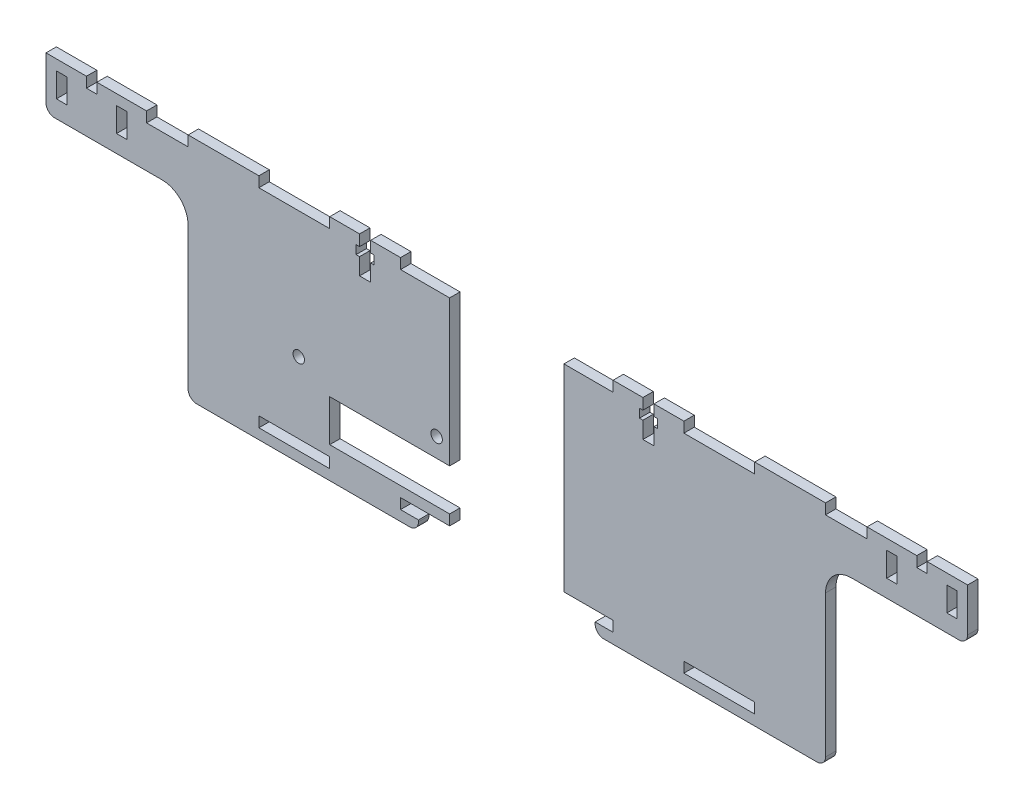
from build123d import *

# Parameters (mm, degrees)
BOSS_EXTRUDE1_DEPTH     = 3
SKETCH3_W               = 3
SKETCH3_H               = 7
SKETCH3_W_2             = 20.444444445
SKETCH3_H_2             = 3
CUT_EXTRUDE1_DEPTH      = 1
CUT_EXTRUDE1_DEPTH_BACK = 4
FILLET1_R               = 7.5
SKETCH4_W               = 3.2
SKETCH4_H               = 10.5
SKETCH4_W_2             = 5.2
SKETCH4_H_2             = 2.5
CUT_EXTRUDE2_DEPTH      = 1
CUT_EXTRUDE2_DEPTH_BACK = 4
SKETCH5_W               = 33
SKETCH5_H               = 66
CUT_EXTRUDE3_DEPTH      = 1
CUT_EXTRUDE3_DEPTH_BACK = 4
SKETCH6_R               = 1.65
SKETCH6_W               = 34.611111111
SKETCH6_H               = 12
CUT_EXTRUDE4_DEPTH      = 1
CUT_EXTRUDE4_DEPTH_BACK = 4
SKETCH9_W               = 9
SKETCH9_H               = 3
CUT_EXTRUDE7_DEPTH      = 1
CUT_EXTRUDE7_DEPTH_BACK = 4
FILLET2_R               = 2.5
FILLET3_R               = 2.5
SKETCH7_W               = 3
SKETCH7_H               = 3
SKETCH7_W_2             = 10
CUT_EXTRUDE5_DEPTH      = 4
CUT_EXTRUDE5_DEPTH_BACK = 1
SKETCH8_W               = 2
SKETCH8_H               = 3
CUT_EXTRUDE6_DEPTH      = 1
CUT_EXTRUDE6_DEPTH_BACK = 4


with BuildPart() as part:
    # Sketch2 → Boss-Extrude1 (new body)
    with BuildSketch(Plane.XY):
        Polygon((-133, 33), (133, 33), (133, 18), (92, 18), (92, -33), (-92, -33), (-92, 18), (-133, 18), align=None)
    extrude(amount=BOSS_EXTRUDE1_DEPTH)

    # Sketch3 → Cut-Extrude1 (cut, two sides)
    with BuildSketch(Plane.XY.offset(3)) as cut_extrude1_sk:
        with Locations((-128.5, 26.5)):
            Rectangle(SKETCH3_W, SKETCH3_H)
        with Locations((-111.15, 26.5)):
            Rectangle(SKETCH3_W, SKETCH3_H)
        with Locations((-61.333333334, 31.5)):
            Rectangle(SKETCH3_W_2, SKETCH3_H_2)
        with Locations((-20.444444445, 31.5)):
            Rectangle(SKETCH3_W_2, SKETCH3_H_2)
        with Locations((20.444444445, 31.5)):
            Rectangle(SKETCH3_W_2, SKETCH3_H_2)
        with Locations((61.333333334, 31.5)):
            Rectangle(SKETCH3_W_2, SKETCH3_H_2)
        with Locations((128.5, 26.5)):
            Rectangle(SKETCH3_W, SKETCH3_H)
        with Locations((111.15, 26.5)):
            Rectangle(SKETCH3_W, SKETCH3_H)
        with Locations((-61.333333334, -28.5)):
            Rectangle(SKETCH3_W_2, SKETCH3_H_2)
        with Locations((-20.444444445, -28.5)):
            Rectangle(SKETCH3_W_2, SKETCH3_H_2)
        with Locations((20.444444445, -28.5)):
            Rectangle(SKETCH3_W_2, SKETCH3_H_2)
        with Locations((61.333333334, -28.5)):
            Rectangle(SKETCH3_W_2, SKETCH3_H_2)
    extrude(amount=CUT_EXTRUDE1_DEPTH, mode=Mode.SUBTRACT)
    extrude(cut_extrude1_sk.sketch, amount=-CUT_EXTRUDE1_DEPTH_BACK, mode=Mode.SUBTRACT)

    # Fillet1
    fillet1_edges = [part.edges().sort_by_distance(p)[0] for p in [
        (92, 18, 1.5),
        (-92, 18, 1.5),
    ]]
    fillet(fillet1_edges, radius=FILLET1_R)

    # Sketch4 → Cut-Extrude2 (cut, two sides)
    with BuildSketch(Plane.XY.offset(3)) as cut_extrude2_sk:
        with Locations((-40.888888889, 27.75)):
            Rectangle(SKETCH4_W, SKETCH4_H)
        with Locations((40.888888889, 27.75)):
            Rectangle(SKETCH4_W, SKETCH4_H)
        with Locations((40.888888889, 28.575)):
            Rectangle(SKETCH4_W_2, SKETCH4_H_2)
        with Locations((-40.888888889, 28.575)):
            Rectangle(SKETCH4_W_2, SKETCH4_H_2)
    extrude(amount=CUT_EXTRUDE2_DEPTH, mode=Mode.SUBTRACT)
    extrude(cut_extrude2_sk.sketch, amount=-CUT_EXTRUDE2_DEPTH_BACK, mode=Mode.SUBTRACT)

    # Sketch5 → Cut-Extrude3 (cut, two sides)
    with BuildSketch(Plane.XY.offset(3)) as cut_extrude3_sk:
        Rectangle(SKETCH5_W, SKETCH5_H)
    extrude(amount=CUT_EXTRUDE3_DEPTH, mode=Mode.SUBTRACT)
    extrude(cut_extrude3_sk.sketch, amount=-CUT_EXTRUDE3_DEPTH_BACK, mode=Mode.SUBTRACT)

    # Sketch6 → Cut-Extrude4 (cut, two sides)
    with BuildSketch(Plane.XY.offset(3)) as cut_extrude4_sk:
        with Locations((-20.25, -6.5)):
            Circle(SKETCH6_R)
        with Locations((-60.05, -6.5)):
            Circle(SKETCH6_R)
        with Locations((-33.805555556, -18)):
            Rectangle(SKETCH6_W, SKETCH6_H)
    extrude(amount=CUT_EXTRUDE4_DEPTH, mode=Mode.SUBTRACT)
    extrude(cut_extrude4_sk.sketch, amount=-CUT_EXTRUDE4_DEPTH_BACK, mode=Mode.SUBTRACT)

    # Sketch9 → Cut-Extrude7 (cut, two sides)
    with BuildSketch(Plane.XY.offset(3)) as cut_extrude7_sk:
        with Locations((-21, -31.5)):
            Rectangle(SKETCH9_W, SKETCH9_H)
        with Locations((21, -31.5)):
            Rectangle(SKETCH9_W, SKETCH9_H)
    extrude(amount=CUT_EXTRUDE7_DEPTH, mode=Mode.SUBTRACT)
    extrude(cut_extrude7_sk.sketch, amount=-CUT_EXTRUDE7_DEPTH_BACK, mode=Mode.SUBTRACT)

    # Fillet2
    fillet2_edges = [part.edges().sort_by_distance(p)[0] for p in [
        (92, -33, 1.5),
        (133, 18, 1.5),
        (25.5, -33, 1.5),
    ]]
    fillet(fillet2_edges, radius=FILLET2_R)

    # Fillet3
    fillet3_edges = [part.edges().sort_by_distance(p)[0] for p in [
        (-92, -33, 1.5),
        (-133, 18, 1.5),
        (-25.5, -33, 1.5),
    ]]
    fillet(fillet3_edges, radius=FILLET3_R)

    # Sketch7 → Cut-Extrude5 (cut, two sides)
    with BuildSketch(Plane.XY) as cut_extrude5_sk:
        with Locations((-119.825, 31.5)):
            Rectangle(SKETCH7_W, SKETCH7_H)
        with Locations((119.825, 31.5)):
            Rectangle(SKETCH7_W, SKETCH7_H)
        with Locations((-98.975, 31.5)):
            Rectangle(SKETCH7_W_2, SKETCH7_H)
        with Locations((98.975, 31.5)):
            Rectangle(SKETCH7_W_2, SKETCH7_H)
    extrude(amount=CUT_EXTRUDE5_DEPTH, mode=Mode.SUBTRACT)
    extrude(cut_extrude5_sk.sketch, amount=-CUT_EXTRUDE5_DEPTH_BACK, mode=Mode.SUBTRACT)

    # Sketch8 → Cut-Extrude6 (cut, two sides)
    with BuildSketch(Plane.XY.offset(3)) as cut_extrude6_sk:
        with Locations((-92.975, 31.5)):
            Rectangle(SKETCH8_W, SKETCH8_H)
        with Locations((92.975, 31.5)):
            Rectangle(SKETCH8_W, SKETCH8_H)
    extrude(amount=CUT_EXTRUDE6_DEPTH, mode=Mode.SUBTRACT)
    extrude(cut_extrude6_sk.sketch, amount=-CUT_EXTRUDE6_DEPTH_BACK, mode=Mode.SUBTRACT)


solid = part.part
